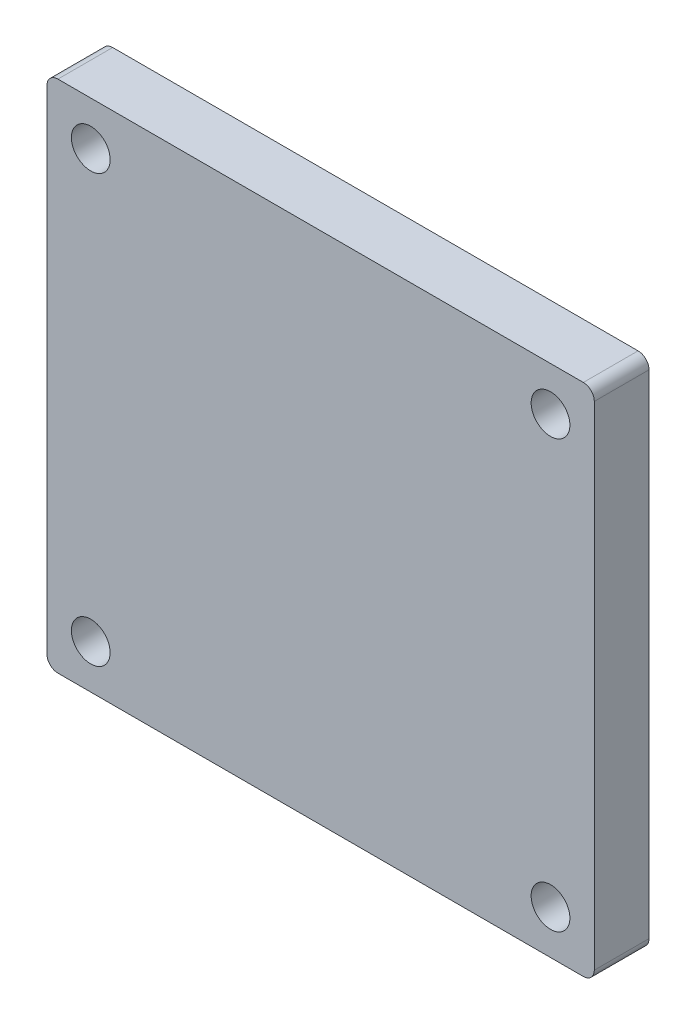
from build123d import *

# Parameters (mm, degrees)
SKETCH1_W             = 63.5
SKETCH1_H             = 59.69
BOSS_EXTRUDE1_DEPTH   = 6.35
FILLET1_R             = 1.27
F_8_CLEARANCE_HOLE1_D = 4.4958


with BuildPart() as part:
    # Sketch1 → Boss-Extrude1 (new body)
    with BuildSketch(Plane.XY):
        with Locations((31.75, 29.845)):
            Rectangle(SKETCH1_W, SKETCH1_H)
    extrude(amount=BOSS_EXTRUDE1_DEPTH)

    # Fillet1
    fillet1_edges = [part.edges().sort_by_distance(p)[0] for p in [
        (0, 59.69, 3.175),
        (63.5, 59.69, 3.175),
        (63.5, 0, 3.175),
        (0, 0, 3.175),
    ]]
    fillet(fillet1_edges, radius=FILLET1_R)

    # #8 Clearance Hole1 (through all)
    with Locations(Plane.XY.offset(6.35)):
        with Locations((5.08, 54.61), (58.42, 54.61), (58.42, 5.08), (5.08, 5.08)):
            Hole(F_8_CLEARANCE_HOLE1_D / 2)


solid = part.part
